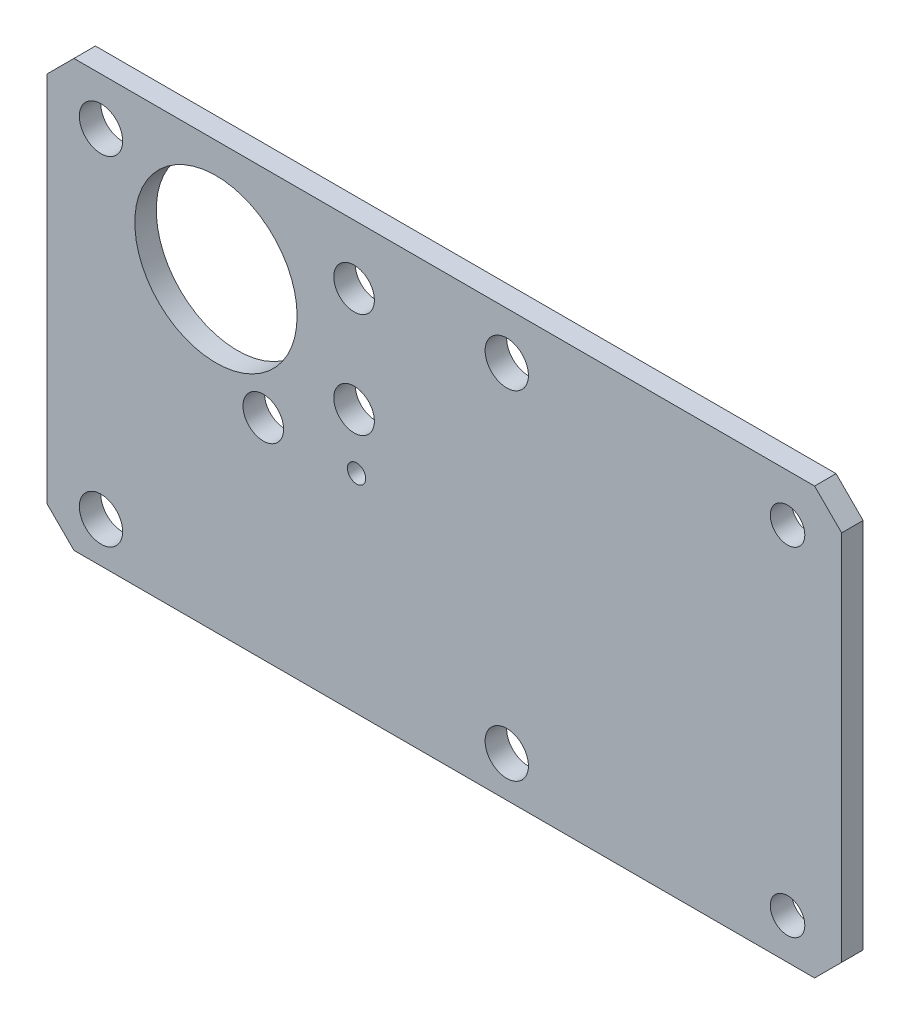
from build123d import *

# Parameters (mm, degrees)
SKETCH1_W               = 117.516
SKETCH1_H               = 63
SKETCH1_R               = 3.2004
SKETCH1_R_2             = 3
SKETCH1_R_3             = 12
BOSS_EXTRUDE1_DEPTH     = 3.175
CHAMFER1_SIZE           = 4
F_1_4_20_TAPPED_HOLE1_D = 5.1054
F_6_32_TAPPED_HOLE1_D   = 2.7051


with BuildPart() as part:
    # Sketch1 → Boss-Extrude1 (new body)
    with BuildSketch(Plane.XY):
        with Locations((26.758, -14.99999999)):
            Rectangle(SKETCH1_W, SKETCH1_H)
        with Locations((-24, 9.50000001)):
            Circle(SKETCH1_R, mode=Mode.SUBTRACT)
        with Locations((13.423393759, 7.75)):
            Circle(SKETCH1_R_2, mode=Mode.SUBTRACT)
        with Locations((-7, 0)):
            Circle(SKETCH1_R_3, mode=Mode.SUBTRACT)
        with Locations((13.423393759, -7.75)):
            Circle(SKETCH1_R_2, mode=Mode.SUBTRACT)
        with Locations((-24, -40.49999999)):
            Circle(SKETCH1_R, mode=Mode.SUBTRACT)
        with Locations((0, -15.5)):
            Circle(SKETCH1_R_2, mode=Mode.SUBTRACT)
        with Locations((36, -40.49999999)):
            Circle(SKETCH1_R, mode=Mode.SUBTRACT)
        with Locations((36, 9.50000001)):
            Circle(SKETCH1_R, mode=Mode.SUBTRACT)
    extrude(amount=-BOSS_EXTRUDE1_DEPTH)

    # Chamfer1
    chamfer1_edges = [part.edges().sort_by_distance(p)[0] for p in [
        (85.516, -46.49999999, -1.5875),
        (85.516, 16.50000001, -1.5875),
        (-32, -46.49999999, -1.5875),
        (-32, 16.50000001, -1.5875),
    ]]
    chamfer(chamfer1_edges, length=CHAMFER1_SIZE)

    # 1_4-20 Tapped Hole1 (through all)
    with Locations(Plane.XY):
        with Locations((77.516, 9.50000001), (77.516, -40.49999999)):
            Hole(F_1_4_20_TAPPED_HOLE1_D / 2)

    # 6-32 Tapped Hole1 (through all)
    with Locations(Plane.XY):
        with Locations((13.79086472, -15.75179999)):
            Hole(F_6_32_TAPPED_HOLE1_D / 2)


solid = part.part
